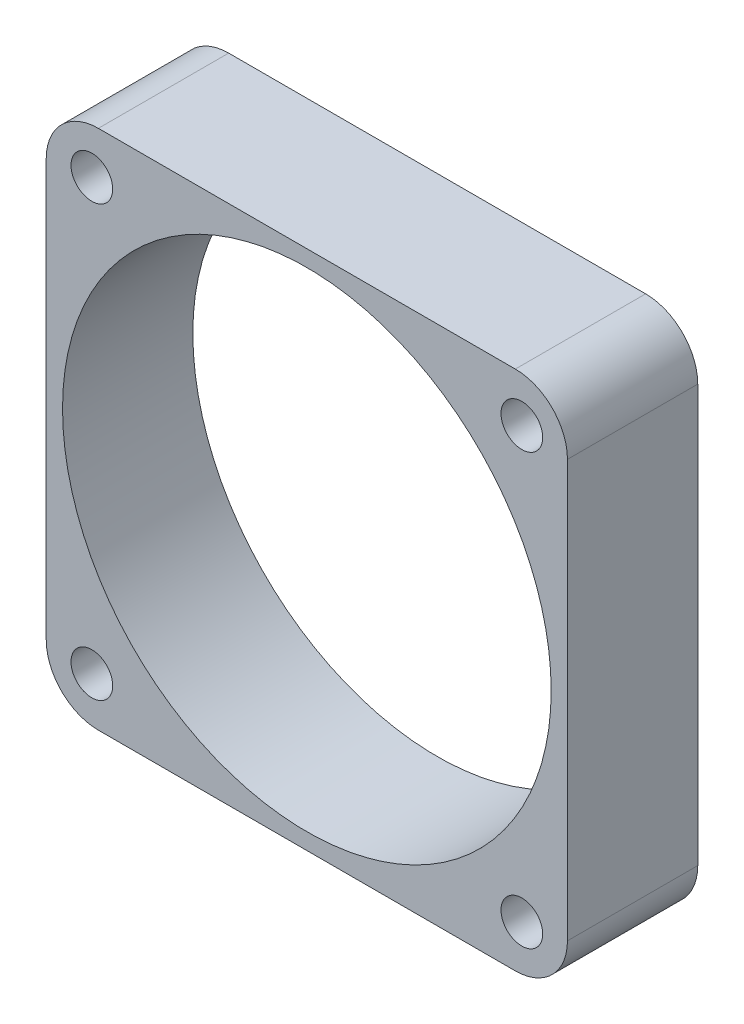
from build123d import *

# Parameters (mm, degrees)
SKETCH_1_R      = 1.6
SKETCH_1_R_2    = 18.75
EXTRUDE_1_DEPTH = 10


with BuildPart() as part:
    # Эскиз1 → Бобышка-Вытянуть1 (new body)
    with BuildSketch(Plane.XY):
        with BuildLine():
            Line((4, 0), (36, 0))
            ThreePointArc((36, 0), (38.828427125, 1.171572875), (40, 4))
            Line((40, 4), (40, 36))
            ThreePointArc((40, 36), (38.828427125, 38.828427125), (36, 40))
            Line((36, 40), (4, 40))
            ThreePointArc((4, 40), (1.171572875, 38.828427125), (0, 36))
            Line((0, 36), (0, 4))
            ThreePointArc((0, 4), (1.171572875, 1.171572875), (4, 0))
        make_face()
        with Locations((3.5, 36.5)):
            Circle(SKETCH_1_R, mode=Mode.SUBTRACT)
        with Locations((36.5, 36.5)):
            Circle(SKETCH_1_R, mode=Mode.SUBTRACT)
        with Locations((36.5, 3.5)):
            Circle(SKETCH_1_R, mode=Mode.SUBTRACT)
        with Locations((3.5, 3.5)):
            Circle(SKETCH_1_R, mode=Mode.SUBTRACT)
        with Locations((20, 20)):
            Circle(SKETCH_1_R_2, mode=Mode.SUBTRACT)
    extrude(amount=EXTRUDE_1_DEPTH)


solid = part.part
